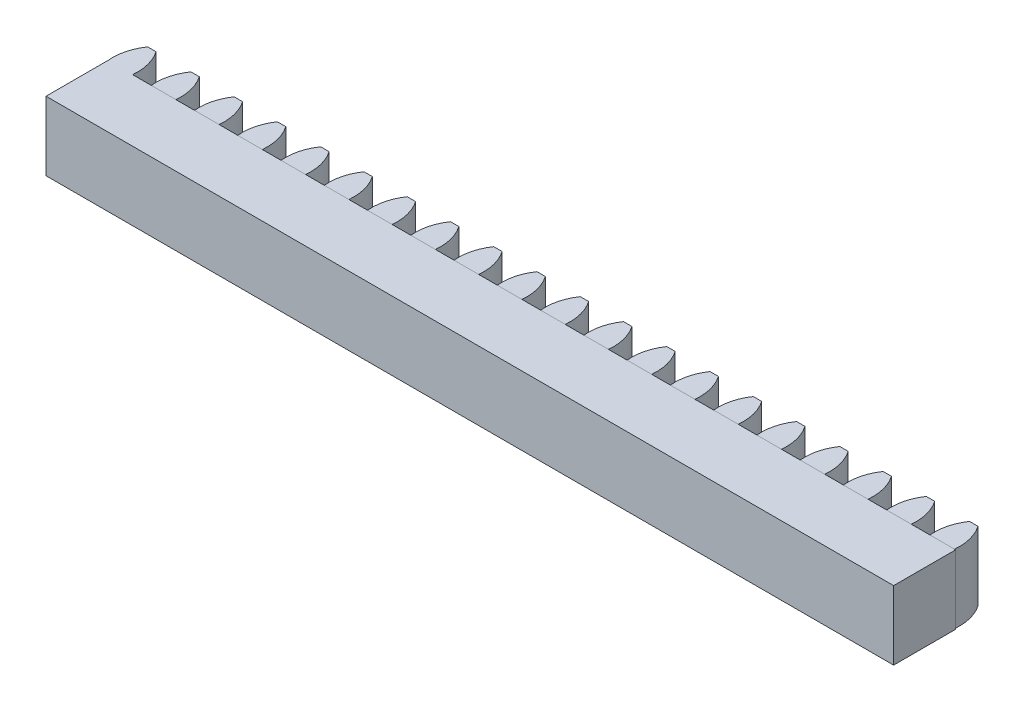
from build123d import *

# Parameters (mm, degrees)
EXTRUDE_1_DEPTH    = 10
EXTRUDE_1_2_DEPTH  = 10
EXTRUDE_1_3_DEPTH  = 10
EXTRUDE_1_4_DEPTH  = 10
EXTRUDE_1_5_DEPTH  = 10
EXTRUDE_1_6_DEPTH  = 10
EXTRUDE_1_7_DEPTH  = 10
EXTRUDE_1_8_DEPTH  = 10
EXTRUDE_1_9_DEPTH  = 10
EXTRUDE_1_10_DEPTH = 10
EXTRUDE_1_11_DEPTH = 10
EXTRUDE_1_12_DEPTH = 10
EXTRUDE_1_13_DEPTH = 10
EXTRUDE_1_14_DEPTH = 10
EXTRUDE_1_15_DEPTH = 10
EXTRUDE_1_16_DEPTH = 10
EXTRUDE_1_17_DEPTH = 10
EXTRUDE_1_18_DEPTH = 10
EXTRUDE_1_19_DEPTH = 10
EXTRUDE_1_20_DEPTH = 10
SKETCH_2_W         = 123.049402761
SKETCH_2_H         = 9
EXTRUDE_2_DEPTH    = 10


with BuildPart() as part:
    # 草图1 → 凸台-拉伸1 (new body)
    with BuildSketch(Plane(origin=(0, 0, 0), x_dir=(1, 0, 0), z_dir=(0, 1, 0))):
        with BuildLine():
            Line((0, 0), (3.56841482, 0))
            ThreePointArc((3.56841482, 0), (3.390081639, 2.395699354), (2.39445741, 4.582))
            Line((2.39445741, 4.582), (1.17395741, 4.582))
            ThreePointArc((1.17395741, 4.582), (0.178333181, 2.395699354), (0, 0))
        make_face()
    extrude(amount=EXTRUDE_1_DEPTH)

    # 草图2 → 凸台-拉伸2 (add)
    with BuildSketch(Plane(origin=(0, 10, 0), x_dir=(1, 0, 0), z_dir=(0, 1, 0))):
        with Locations((61.524701381, -4.5)):
            Rectangle(SKETCH_2_W, SKETCH_2_H)
    extrude(amount=-EXTRUDE_2_DEPTH)


with BuildPart() as body_2:
    # 草图1 → Extrude 1 2 (new body)
    with BuildSketch(Plane(origin=(0, 0, 0), x_dir=(1, 0, 0), z_dir=(0, 1, 0))):
        with BuildLine():
            Line((6.28, 0), (9.84841482, 0))
            ThreePointArc((9.84841482, 0), (9.670081639, 2.395699354), (8.67445741, 4.582))
            Line((8.67445741, 4.582), (7.45395741, 4.582))
            ThreePointArc((7.45395741, 4.582), (6.458333181, 2.395699354), (6.28, 0))
        make_face()
    extrude(amount=EXTRUDE_1_2_DEPTH)


with BuildPart() as body_3:
    # 草图1 → Extrude 1 3 (new body)
    with BuildSketch(Plane(origin=(0, 0, 0), x_dir=(1, 0, 0), z_dir=(0, 1, 0))):
        with BuildLine():
            Line((12.56, 0), (16.12841482, 0))
            ThreePointArc((16.12841482, 0), (15.950081639, 2.395699354), (14.95445741, 4.582))
            Line((14.95445741, 4.582), (13.73395741, 4.582))
            ThreePointArc((13.73395741, 4.582), (12.738333181, 2.395699354), (12.56, 0))
        make_face()
    extrude(amount=EXTRUDE_1_3_DEPTH)


with BuildPart() as body_4:
    # 草图1 → Extrude 1 4 (new body)
    with BuildSketch(Plane(origin=(0, 0, 0), x_dir=(1, 0, 0), z_dir=(0, 1, 0))):
        with BuildLine():
            Line((18.84, 0), (22.40841482, 0))
            ThreePointArc((22.40841482, 0), (22.230081639, 2.395699354), (21.23445741, 4.582))
            Line((21.23445741, 4.582), (20.01395741, 4.582))
            ThreePointArc((20.01395741, 4.582), (19.018333181, 2.395699354), (18.84, 0))
        make_face()
    extrude(amount=EXTRUDE_1_4_DEPTH)


with BuildPart() as body_5:
    # 草图1 → Extrude 1 5 (new body)
    with BuildSketch(Plane(origin=(0, 0, 0), x_dir=(1, 0, 0), z_dir=(0, 1, 0))):
        with BuildLine():
            Line((25.12, 0), (28.68841482, 0))
            ThreePointArc((28.68841482, 0), (28.510081639, 2.395699354), (27.51445741, 4.582))
            Line((27.51445741, 4.582), (26.29395741, 4.582))
            ThreePointArc((26.29395741, 4.582), (25.298333181, 2.395699354), (25.12, 0))
        make_face()
    extrude(amount=EXTRUDE_1_5_DEPTH)


with BuildPart() as body_6:
    # 草图1 → Extrude 1 6 (new body)
    with BuildSketch(Plane(origin=(0, 0, 0), x_dir=(1, 0, 0), z_dir=(0, 1, 0))):
        with BuildLine():
            Line((31.4, 0), (34.96841482, 0))
            ThreePointArc((34.96841482, 0), (34.790081639, 2.395699354), (33.79445741, 4.582))
            Line((33.79445741, 4.582), (32.57395741, 4.582))
            ThreePointArc((32.57395741, 4.582), (31.578333181, 2.395699354), (31.4, 0))
        make_face()
    extrude(amount=EXTRUDE_1_6_DEPTH)


with BuildPart() as body_7:
    # 草图1 → Extrude 1 7 (new body)
    with BuildSketch(Plane(origin=(0, 0, 0), x_dir=(1, 0, 0), z_dir=(0, 1, 0))):
        with BuildLine():
            Line((37.68, 0), (41.24841482, 0))
            ThreePointArc((41.24841482, 0), (41.070081639, 2.395699354), (40.07445741, 4.582))
            Line((40.07445741, 4.582), (38.85395741, 4.582))
            ThreePointArc((38.85395741, 4.582), (37.858333181, 2.395699354), (37.68, 0))
        make_face()
    extrude(amount=EXTRUDE_1_7_DEPTH)


with BuildPart() as body_8:
    # 草图1 → Extrude 1 8 (new body)
    with BuildSketch(Plane(origin=(0, 0, 0), x_dir=(1, 0, 0), z_dir=(0, 1, 0))):
        with BuildLine():
            Line((43.96, 0), (47.52841482, 0))
            ThreePointArc((47.52841482, 0), (47.350081639, 2.395699354), (46.35445741, 4.582))
            Line((46.35445741, 4.582), (45.13395741, 4.582))
            ThreePointArc((45.13395741, 4.582), (44.138333181, 2.395699354), (43.96, 0))
        make_face()
    extrude(amount=EXTRUDE_1_8_DEPTH)


with BuildPart() as body_9:
    # 草图1 → Extrude 1 9 (new body)
    with BuildSketch(Plane(origin=(0, 0, 0), x_dir=(1, 0, 0), z_dir=(0, 1, 0))):
        with BuildLine():
            Line((50.24, 0), (53.80841482, 0))
            ThreePointArc((53.80841482, 0), (53.630081639, 2.395699354), (52.63445741, 4.582))
            Line((52.63445741, 4.582), (51.41395741, 4.582))
            ThreePointArc((51.41395741, 4.582), (50.418333181, 2.395699354), (50.24, 0))
        make_face()
    extrude(amount=EXTRUDE_1_9_DEPTH)


with BuildPart() as body_10:
    # 草图1 → Extrude 1 10 (new body)
    with BuildSketch(Plane(origin=(0, 0, 0), x_dir=(1, 0, 0), z_dir=(0, 1, 0))):
        with BuildLine():
            Line((56.52, 0), (60.08841482, 0))
            ThreePointArc((60.08841482, 0), (59.910081639, 2.395699354), (58.91445741, 4.582))
            Line((58.91445741, 4.582), (57.69395741, 4.582))
            ThreePointArc((57.69395741, 4.582), (56.698333181, 2.395699354), (56.52, 0))
        make_face()
    extrude(amount=EXTRUDE_1_10_DEPTH)


with BuildPart() as body_11:
    # 草图1 → Extrude 1 11 (new body)
    with BuildSketch(Plane(origin=(0, 0, 0), x_dir=(1, 0, 0), z_dir=(0, 1, 0))):
        with BuildLine():
            Line((62.8, 0), (66.36841482, 0))
            ThreePointArc((66.36841482, 0), (66.190081639, 2.395699354), (65.19445741, 4.582))
            Line((65.19445741, 4.582), (63.97395741, 4.582))
            ThreePointArc((63.97395741, 4.582), (62.978333181, 2.395699354), (62.8, 0))
        make_face()
    extrude(amount=EXTRUDE_1_11_DEPTH)


with BuildPart() as body_12:
    # 草图1 → Extrude 1 12 (new body)
    with BuildSketch(Plane(origin=(0, 0, 0), x_dir=(1, 0, 0), z_dir=(0, 1, 0))):
        with BuildLine():
            Line((69.08, 0), (72.64841482, 0))
            ThreePointArc((72.64841482, 0), (72.470081639, 2.395699354), (71.47445741, 4.582))
            Line((71.47445741, 4.582), (70.25395741, 4.582))
            ThreePointArc((70.25395741, 4.582), (69.258333181, 2.395699354), (69.08, 0))
        make_face()
    extrude(amount=EXTRUDE_1_12_DEPTH)


with BuildPart() as body_13:
    # 草图1 → Extrude 1 13 (new body)
    with BuildSketch(Plane(origin=(0, 0, 0), x_dir=(1, 0, 0), z_dir=(0, 1, 0))):
        with BuildLine():
            Line((75.36, 0), (78.92841482, 0))
            ThreePointArc((78.92841482, 0), (78.750081639, 2.395699354), (77.75445741, 4.582))
            Line((77.75445741, 4.582), (76.53395741, 4.582))
            ThreePointArc((76.53395741, 4.582), (75.538333181, 2.395699354), (75.36, 0))
        make_face()
    extrude(amount=EXTRUDE_1_13_DEPTH)


with BuildPart() as body_14:
    # 草图1 → Extrude 1 14 (new body)
    with BuildSketch(Plane(origin=(0, 0, 0), x_dir=(1, 0, 0), z_dir=(0, 1, 0))):
        with BuildLine():
            Line((81.64, 0), (85.20841482, 0))
            ThreePointArc((85.20841482, 0), (85.030081639, 2.395699354), (84.03445741, 4.582))
            Line((84.03445741, 4.582), (82.81395741, 4.582))
            ThreePointArc((82.81395741, 4.582), (81.818333181, 2.395699354), (81.64, 0))
        make_face()
    extrude(amount=EXTRUDE_1_14_DEPTH)


with BuildPart() as body_15:
    # 草图1 → Extrude 1 15 (new body)
    with BuildSketch(Plane(origin=(0, 0, 0), x_dir=(1, 0, 0), z_dir=(0, 1, 0))):
        with BuildLine():
            Line((87.92, 0), (91.48841482, 0))
            ThreePointArc((91.48841482, 0), (91.310081639, 2.395699354), (90.31445741, 4.582))
            Line((90.31445741, 4.582), (89.09395741, 4.582))
            ThreePointArc((89.09395741, 4.582), (88.098333181, 2.395699354), (87.92, 0))
        make_face()
    extrude(amount=EXTRUDE_1_15_DEPTH)


with BuildPart() as body_16:
    # 草图1 → Extrude 1 16 (new body)
    with BuildSketch(Plane(origin=(0, 0, 0), x_dir=(1, 0, 0), z_dir=(0, 1, 0))):
        with BuildLine():
            Line((94.2, 0), (97.76841482, 0))
            ThreePointArc((97.76841482, 0), (97.590081639, 2.395699354), (96.59445741, 4.582))
            Line((96.59445741, 4.582), (95.37395741, 4.582))
            ThreePointArc((95.37395741, 4.582), (94.378333181, 2.395699354), (94.2, 0))
        make_face()
    extrude(amount=EXTRUDE_1_16_DEPTH)


with BuildPart() as body_17:
    # 草图1 → Extrude 1 17 (new body)
    with BuildSketch(Plane(origin=(0, 0, 0), x_dir=(1, 0, 0), z_dir=(0, 1, 0))):
        with BuildLine():
            Line((100.48, 0), (104.04841482, 0))
            ThreePointArc((104.04841482, 0), (103.870081639, 2.395699354), (102.87445741, 4.582))
            Line((102.87445741, 4.582), (101.65395741, 4.582))
            ThreePointArc((101.65395741, 4.582), (100.658333181, 2.395699354), (100.48, 0))
        make_face()
    extrude(amount=EXTRUDE_1_17_DEPTH)


with BuildPart() as body_18:
    # 草图1 → Extrude 1 18 (new body)
    with BuildSketch(Plane(origin=(0, 0, 0), x_dir=(1, 0, 0), z_dir=(0, 1, 0))):
        with BuildLine():
            Line((106.76, 0), (110.32841482, 0))
            ThreePointArc((110.32841482, 0), (110.150081639, 2.395699354), (109.15445741, 4.582))
            Line((109.15445741, 4.582), (107.93395741, 4.582))
            ThreePointArc((107.93395741, 4.582), (106.938333181, 2.395699354), (106.76, 0))
        make_face()
    extrude(amount=EXTRUDE_1_18_DEPTH)


with BuildPart() as body_19:
    # 草图1 → Extrude 1 19 (new body)
    with BuildSketch(Plane(origin=(0, 0, 0), x_dir=(1, 0, 0), z_dir=(0, 1, 0))):
        with BuildLine():
            Line((113.04, 0), (116.60841482, 0))
            ThreePointArc((116.60841482, 0), (116.430081639, 2.395699354), (115.43445741, 4.582))
            Line((115.43445741, 4.582), (114.21395741, 4.582))
            ThreePointArc((114.21395741, 4.582), (113.218333181, 2.395699354), (113.04, 0))
        make_face()
    extrude(amount=EXTRUDE_1_19_DEPTH)


with BuildPart() as body_20:
    # 草图1 → Extrude 1 20 (new body)
    with BuildSketch(Plane(origin=(0, 0, 0), x_dir=(1, 0, 0), z_dir=(0, 1, 0))):
        with BuildLine():
            Line((119.32, 0), (122.88841482, 0))
            ThreePointArc((122.88841482, 0), (122.710081639, 2.395699354), (121.71445741, 4.582))
            Line((121.71445741, 4.582), (120.49395741, 4.582))
            ThreePointArc((120.49395741, 4.582), (119.498333181, 2.395699354), (119.32, 0))
        make_face()
    extrude(amount=EXTRUDE_1_20_DEPTH)


solid = Compound([part.part, body_2.part, body_3.part, body_4.part, body_5.part, body_6.part, body_7.part, body_8.part, body_9.part, body_10.part, body_11.part, body_12.part, body_13.part, body_14.part, body_15.part, body_16.part, body_17.part, body_18.part, body_19.part, body_20.part])
